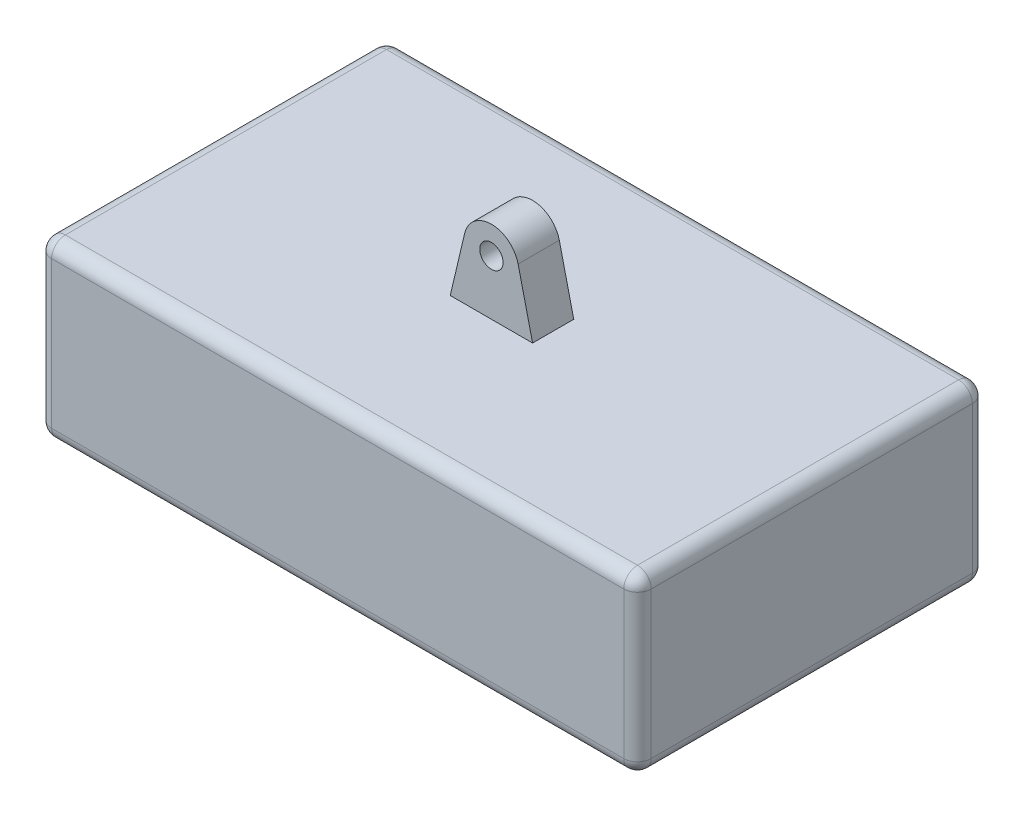
from build123d import *

# Parameters (mm, degrees)
SKETCH1_W           = 218.44
SKETCH1_H           = 127
BOSS_EXTRUDE1_DEPTH = 63.5
SKETCH2_W           = 30
SKETCH2_H           = 15
BOSS_EXTRUDE2_DEPTH = 30
CUT_EXTRUDE1_REACH  = 162.35
FILLET1_R           = 5


with BuildPart() as part:
    # Sketch1 → Boss-Extrude1 (new body)
    with BuildSketch(Plane(origin=(0, 0, 0), x_dir=(1, 0, 0), z_dir=(0, 1, 0))):
        Rectangle(SKETCH1_W, SKETCH1_H)
    extrude(amount=BOSS_EXTRUDE1_DEPTH)

    # Sketch2 → Boss-Extrude2 (add)
    with BuildSketch(Plane(origin=(0, 63.5, 0), x_dir=(1, 0, 0), z_dir=(0, 1, 0))):
        Rectangle(SKETCH2_W, SKETCH2_H)
    extrude(amount=BOSS_EXTRUDE2_DEPTH)

    # Sketch3 → Cut-Extrude1 (cut, up to next)
    with BuildSketch(Plane(origin=(0, 0, -7.5), x_dir=(-1, 0, 0), z_dir=(0, 0, -1)), mode=Mode.PRIVATE) as cut_extrude1_sk1:
        with BuildLine():
            ThreePointArc((4.25, 83.5), (3.00520382, 86.50520382), (0, 87.75))
            Line((0, 87.75), (0, 79.25))
            ThreePointArc((0, 79.25), (3.00520382, 80.49479618), (4.25, 83.5))
        make_face()
    cut_extrude1_tool1 = extrude(cut_extrude1_sk1.sketch, amount=-CUT_EXTRUDE1_REACH, mode=Mode.PRIVATE) & part.part
    # Sketch3 → Cut-Extrude1 (cut, up to next)
    with BuildSketch(Plane(origin=(0, 0, -7.5), x_dir=(-1, 0, 0), z_dir=(0, 0, -1)), mode=Mode.PRIVATE) as cut_extrude1_sk2:
        with BuildLine():
            Line((0, 79.25), (0, 87.75))
            ThreePointArc((0, 87.75), (-4.25, 83.5), (0, 79.25))
        make_face()
    cut_extrude1_tool2 = extrude(cut_extrude1_sk2.sketch, amount=-CUT_EXTRUDE1_REACH, mode=Mode.PRIVATE) & part.part
    # Sketch3 → Cut-Extrude1 (cut, up to next)
    with BuildSketch(Plane(origin=(0, 0, -7.5), x_dir=(-1, 0, 0), z_dir=(0, 0, -1)), mode=Mode.PRIVATE) as cut_extrude1_sk3:
        with BuildLine():
            ThreePointArc((4.25, 83.5), (3.00520382, 86.50520382), (0, 87.75))
            Line((0, 87.75), (0, 79.25))
            ThreePointArc((0, 79.25), (3.00520382, 80.49479618), (4.25, 83.5))
        make_face()
    cut_extrude1_tool3 = extrude(cut_extrude1_sk3.sketch, amount=-CUT_EXTRUDE1_REACH, mode=Mode.PRIVATE) & part.part
    # Sketch3 → Cut-Extrude1 (cut, up to next)
    with BuildSketch(Plane(origin=(0, 0, -7.5), x_dir=(-1, 0, 0), z_dir=(0, 0, -1)), mode=Mode.PRIVATE) as cut_extrude1_sk4:
        with BuildLine():
            Line((0, 79.25), (0, 87.75))
            ThreePointArc((0, 87.75), (-4.25, 83.5), (0, 79.25))
        make_face()
    cut_extrude1_tool4 = extrude(cut_extrude1_sk4.sketch, amount=-CUT_EXTRUDE1_REACH, mode=Mode.PRIVATE) & part.part
    # Sketch3 → Cut-Extrude1 (cut, up to next)
    with BuildSketch(Plane(origin=(0, 0, -7.5), x_dir=(-1, 0, 0), z_dir=(0, 0, -1)), mode=Mode.PRIVATE) as cut_extrude1_sk5:
        with BuildLine():
            Line((15, 93.5), (0, 93.5))
            ThreePointArc((0, 93.5), (6.205203126, 91.341903734), (9.732121112, 85.799090834))
            Line((9.732121112, 85.799090834), (15, 63.5))
            Line((15, 63.5), (15, 93.5))
        make_face()
    cut_extrude1_tool5 = extrude(cut_extrude1_sk5.sketch, amount=-CUT_EXTRUDE1_REACH, mode=Mode.PRIVATE) & part.part
    # Sketch3 → Cut-Extrude1 (cut, up to next)
    with BuildSketch(Plane(origin=(0, 0, -7.5), x_dir=(-1, 0, 0), z_dir=(0, 0, -1)), mode=Mode.PRIVATE) as cut_extrude1_sk6:
        with BuildLine():
            ThreePointArc((-9.732121112, 85.799090834), (-6.205203126, 91.341903734), (0, 93.5))
            Line((0, 93.5), (-15, 93.5))
            Line((-15, 93.5), (-15, 63.5))
            Line((-15, 63.5), (-9.732121112, 85.799090834))
        make_face()
    cut_extrude1_tool6 = extrude(cut_extrude1_sk6.sketch, amount=-CUT_EXTRUDE1_REACH, mode=Mode.PRIVATE) & part.part
    add(cut_extrude1_tool1.solids().sort_by_distance((-1.803756, 83.5, -7.5))[0], mode=Mode.SUBTRACT)
    add(cut_extrude1_tool2.solids().sort_by_distance((1.803756, 83.5, -7.5))[0], mode=Mode.SUBTRACT)
    add(cut_extrude1_tool3.solids().sort_by_distance((-1.803756, 83.5, -7.5))[0], mode=Mode.SUBTRACT)
    add(cut_extrude1_tool4.solids().sort_by_distance((1.803756, 83.5, -7.5))[0], mode=Mode.SUBTRACT)
    add(cut_extrude1_tool5.solids().sort_by_distance((-12.015946, 84.357088, -7.5))[0], mode=Mode.SUBTRACT)
    add(cut_extrude1_tool6.solids().sort_by_distance((12.015946, 84.357088, -7.5))[0], mode=Mode.SUBTRACT)

    # Fillet1
    fillet1_edges = [part.edges().sort_by_distance(p)[0] for p in [
        (109.22, 63.5, 0),
        (0, 63.5, -63.5),
        (-109.22, 63.5, 0),
        (0, 0, -63.5),
        (109.22, 0, 0),
        (0, 0, 63.5),
        (-109.22, 0, 0),
        (0, 63.5, 63.5),
        (-109.22, 31.75, -63.5),
        (109.22, 31.75, -63.5),
        (109.22, 31.75, 63.5),
        (-109.22, 31.75, 63.5),
    ]]
    fillet(fillet1_edges, radius=FILLET1_R)


solid = part.part
